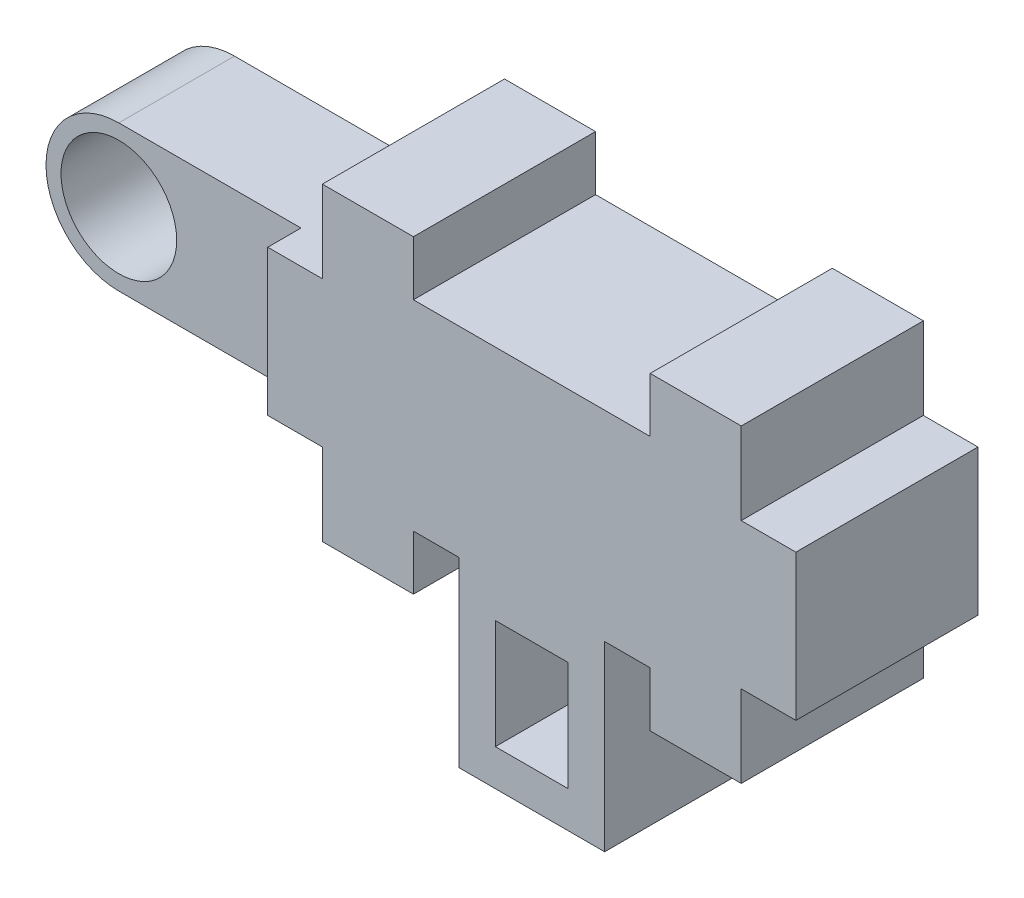
from build123d import *

# Parameters (mm, degrees)
BOSS_EXTRUDE1_DEPTH = 5
SKETCH2_W           = 3.175
SKETCH2_H           = 4
BOSS_EXTRUDE2_DEPTH = 7
SKETCH5_R           = 1.5875
CUT_EXTRUDE3_DEPTH  = 3.175
SKETCH6_W           = 2
SKETCH6_H           = 3
CUT_EXTRUDE4_DEPTH  = 5
SKETCH7_R           = 0.75
CUT_EXTRUDE5_DEPTH  = 1


with BuildPart() as part:
    # Sketch1 → Boss-Extrude1 (new body)
    with BuildSketch(Plane.XY):
        Polygon((-0.65091967, 7.716869785), (-3.15091967, 7.716869785), (-3.15091967, 5.466869785), (-4.65091967, 5.466869785), (-4.65091967, 1.466869785), (-3.15091967, 1.466869785), (-3.15091967, -0.783130215), (-0.65091967, -0.783130215), (-0.65091967, 0.716869785), (0.59908033, 0.716869785), (0.59908033, -4.283130215), (4.59908033, -4.283130215), (4.59908033, 0.466869785), (4.59908033, 0.716869785), (5.84908033, 0.716869785), (5.84908033, -0.783130215), (8.34908033, -0.783130215), (8.34908033, 1.466869785), (9.84908033, 1.466869785), (9.84908033, 5.466869785), (8.34908033, 5.466869785), (8.34908033, 7.716869785), (5.84908033, 7.716869785), (5.84908033, 6.216869785), (-0.65091967, 6.216869785), align=None)
    extrude(amount=-BOSS_EXTRUDE1_DEPTH)

    # Sketch2 → Boss-Extrude2 (add)
    with BuildSketch(Plane.ZY.offset(4.65091967)):
        with Locations((-2.5, 3.466869785)):
            Rectangle(SKETCH2_W, SKETCH2_H)
    extrude(amount=BOSS_EXTRUDE2_DEPTH)

    # Sketch5 → Cut-Extrude3 (cut)
    with BuildSketch(Plane.XY.offset(-0.9125)):
        with BuildLine():
            ThreePointArc((-11.65091967, 3.466869785), (-11.065133233, 4.881083347), (-9.65091967, 5.466869785))
            Line((-9.65091967, 5.466869785), (-11.65091967, 5.466869785))
            Line((-11.65091967, 5.466869785), (-11.65091967, 3.466869785))
        make_face()
        with BuildLine():
            ThreePointArc((-9.65091967, 1.466869785), (-11.065133233, 2.052656222), (-11.65091967, 3.466869785))
            Line((-11.65091967, 3.466869785), (-11.65091967, 1.466869785))
            Line((-11.65091967, 1.466869785), (-9.65091967, 1.466869785))
        make_face()
        with Locations((-9.65091967, 3.466869785)):
            Circle(SKETCH5_R)
    extrude(amount=-CUT_EXTRUDE3_DEPTH, mode=Mode.SUBTRACT)

    # Sketch6 → Cut-Extrude4 (cut)
    with BuildSketch(Plane.XY):
        with Locations((2.59908033, -1.783130215)):
            Rectangle(SKETCH6_W, SKETCH6_H)
    extrude(amount=-CUT_EXTRUDE4_DEPTH, mode=Mode.SUBTRACT)

    # Sketch7 → Cut-Extrude5 (cut)
    with BuildSketch(Plane.XZ.offset(4.283130215)):
        with Locations((2.59908033, -2.5)):
            Circle(SKETCH7_R)
    extrude(amount=-CUT_EXTRUDE5_DEPTH, mode=Mode.SUBTRACT)


solid = part.part
